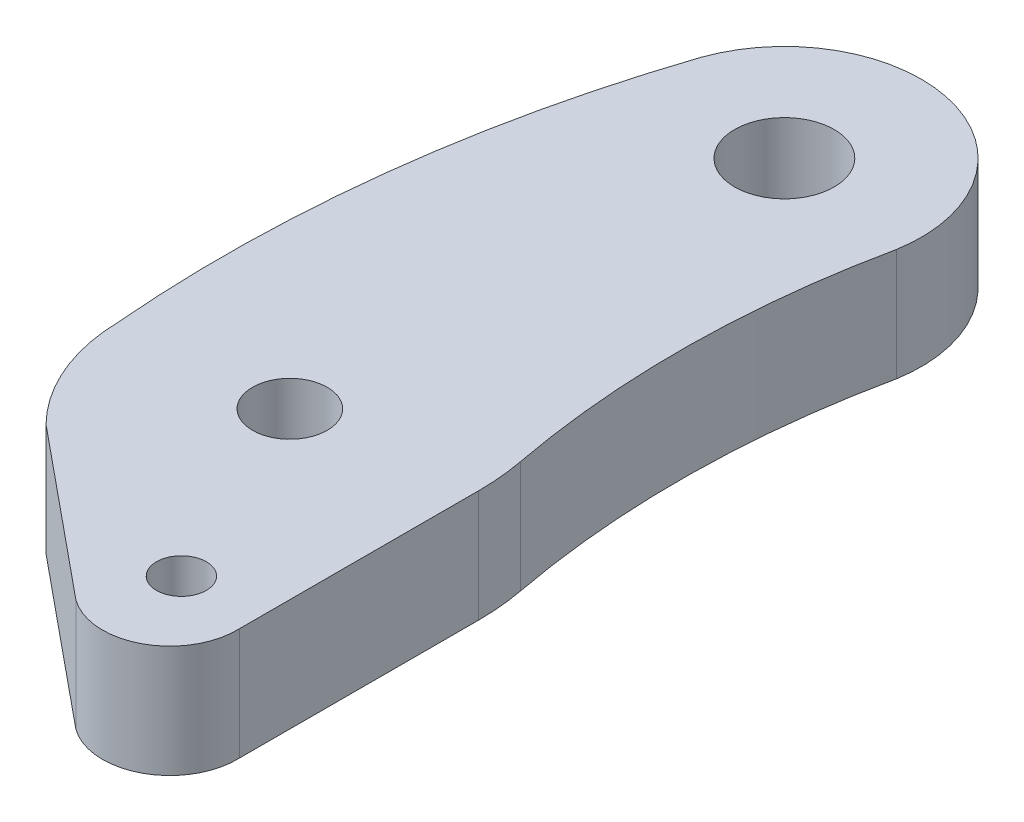
from build123d import *

# Parameters (mm, degrees)
SKETCH1_R           = 1.5
SKETCH1_R_2         = 1
SKETCH1_R_3         = 2
BOSS_EXTRUDE1_DEPTH = 4.5
FILLET1_R           = 10


with BuildPart() as part:
    # Sketch1 → Boss-Extrude1 (new body)
    with BuildSketch(Plane(origin=(0, 0, 0), x_dir=(1, 0, 0), z_dir=(0, 1, 0))):
        with BuildLine():
            ThreePointArc((-6.456463654, -0.468407199), (-5.880915222, -3.152272765), (-4.357266756, -5.43544725))
            Line((-4.357266756, -5.43544725), (2.344258018, -10.938071213))
            ThreePointArc((2.344258018, -10.938071213), (5.202990751, -11.141955791), (6.634993867, -8.659358597))
            Line((6.634993867, -8.659358597), (6.640943349, 1.930649732))
            ThreePointArc((6.640943349, 1.930649732), (5.809058186, 9.628967625), (6.558640267, 17.335734652))
            ThreePointArc((6.558640267, 17.335734652), (6.597770339, 17.526968722), (6.637884512, 17.717998785))
            ThreePointArc((6.637884512, 17.717998785), (2.603251894, 23.964804241), (-3.96716661, 20.4819262))
            ThreePointArc((-3.96716661, 20.4819262), (-4.005352419, 20.366730432), (-4.043270963, 20.251446412))
            ThreePointArc((-4.043270963, 20.251446412), (-6.29279682, 10.012987158), (-6.456463654, -0.468407199))
        make_face()
        Circle(SKETCH1_R, mode=Mode.SUBTRACT)
        with Locations((3.64018052, -7.995416238)):
            Circle(SKETCH1_R_2, mode=Mode.SUBTRACT)
        with Locations((1.216156784, 18.642589744)):
            Circle(SKETCH1_R_3, mode=Mode.SUBTRACT)
    extrude(amount=BOSS_EXTRUDE1_DEPTH)

    # Fillet1
    fillet1_edges = [part.edges().sort_by_distance(p)[0] for p in [
        (6.640943349, 2.25, -1.930649732),
    ]]
    fillet(fillet1_edges, radius=FILLET1_R)


solid = part.part
